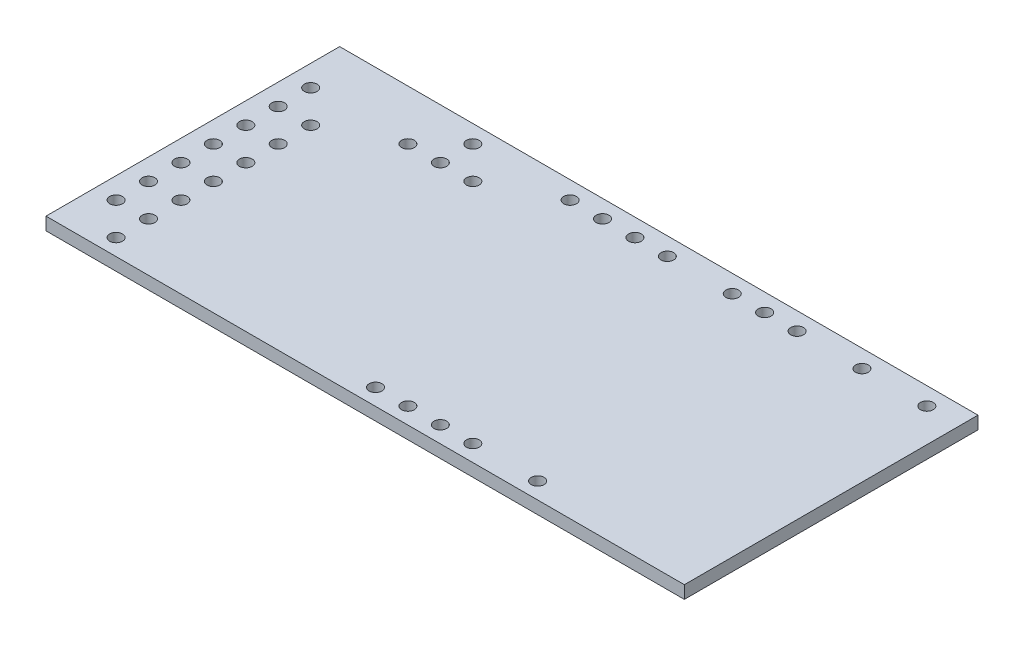
from build123d import *

# Parameters (mm, degrees)
SKETCH1_W           = 50
SKETCH1_H           = 23
BOSS_EXTRUDE1_DEPTH = 1
SKETCH2_R           = 0.5
CUT_EXTRUDE1_DEPTH  = 2


with BuildPart() as part:
    # Sketch1 → Boss-Extrude1 (new body)
    with BuildSketch(Plane(origin=(0, 0, 0), x_dir=(1, 0, 0), z_dir=(0, 1, 0))):
        with Locations((25, 11.5)):
            Rectangle(SKETCH1_W, SKETCH1_H)
    extrude(amount=BOSS_EXTRUDE1_DEPTH)

    # Sketch2 → Cut-Extrude1 (cut, through all)
    with BuildSketch(Plane(origin=(0, 1, 0), x_dir=(1, 0, 0), z_dir=(0, 1, 0))):
        with Locations((1.66, 3.83)):
            Circle(SKETCH2_R)
        with Locations((4.2, 3.83)):
            Circle(SKETCH2_R)
        with Locations((1.66, 6.37)):
            Circle(SKETCH2_R)
        with Locations((1.66, 8.91)):
            Circle(SKETCH2_R)
        with Locations((1.66, 11.45)):
            Circle(SKETCH2_R)
        with Locations((1.66, 13.99)):
            Circle(SKETCH2_R)
        with Locations((1.66, 16.53)):
            Circle(SKETCH2_R)
        with Locations((1.66, 19.07)):
            Circle(SKETCH2_R)
        with Locations((4.2, 6.37)):
            Circle(SKETCH2_R)
        with Locations((4.2, 8.91)):
            Circle(SKETCH2_R)
        with Locations((4.2, 11.45)):
            Circle(SKETCH2_R)
        with Locations((4.2, 13.99)):
            Circle(SKETCH2_R)
        with Locations((4.2, 16.53)):
            Circle(SKETCH2_R)
        with Locations((4.2, 1.29)):
            Circle(SKETCH2_R)
        with Locations((9.28, 19.07)):
            Circle(SKETCH2_R)
        with Locations((11.82, 19.07)):
            Circle(SKETCH2_R)
        with Locations((14.36, 19.07)):
            Circle(SKETCH2_R)
        with Locations((11.82, 21.61)):
            Circle(SKETCH2_R)
        with Locations((19.44, 21.61)):
            Circle(SKETCH2_R)
        with Locations((21.98, 21.61)):
            Circle(SKETCH2_R)
        with Locations((24.52, 21.61)):
            Circle(SKETCH2_R)
        with Locations((27.06, 21.61)):
            Circle(SKETCH2_R)
        with Locations((32.14, 21.61)):
            Circle(SKETCH2_R)
        with Locations((34.68, 21.61)):
            Circle(SKETCH2_R)
        with Locations((37.22, 21.61)):
            Circle(SKETCH2_R)
        with Locations((42.3, 21.61)):
            Circle(SKETCH2_R)
        with Locations((47.38, 21.61)):
            Circle(SKETCH2_R)
        with Locations((24.52, 1.29)):
            Circle(SKETCH2_R)
        with Locations((27.06, 1.29)):
            Circle(SKETCH2_R)
        with Locations((29.6, 1.29)):
            Circle(SKETCH2_R)
        with Locations((32.14, 1.29)):
            Circle(SKETCH2_R)
        with Locations((37.22, 1.29)):
            Circle(SKETCH2_R)
    extrude(amount=-CUT_EXTRUDE1_DEPTH, mode=Mode.SUBTRACT)


solid = part.part
